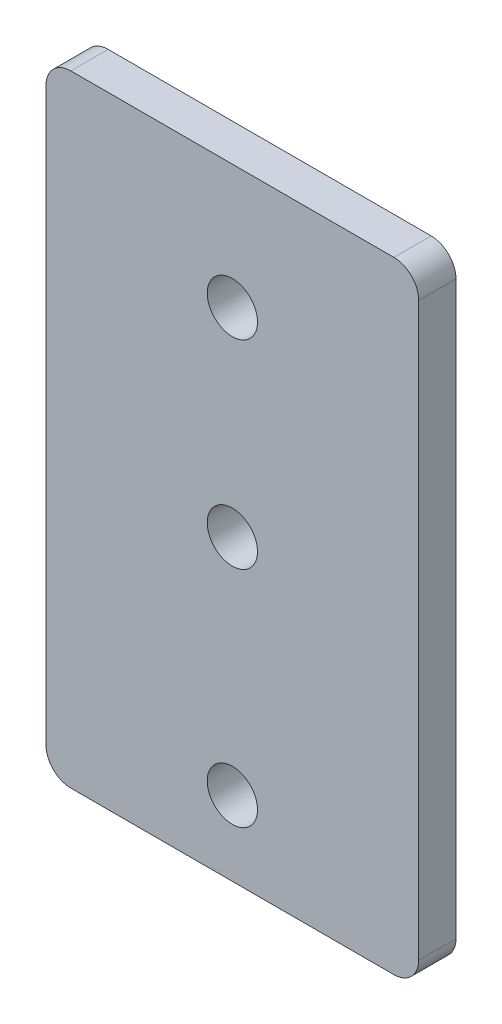
from build123d import *

# Parameters (mm, degrees)
SKETCH_1_W          = 30
SKETCH_1_H          = 50
EXTRUDE_1_DEPTH     = 3
SKETCH_2_R          = 2.025
CUT_EXTRUDE_1_DEPTH = 4
SKETCH_3_R          = 2.025
CUT_EXTRUDE_2_DEPTH = 34
FILLET_1_R          = 2


with BuildPart() as part:
    # 草图1 → 凸台-拉伸1 (new body)
    with BuildSketch(Plane.XY):
        Rectangle(SKETCH_1_W, SKETCH_1_H)
    extrude(amount=EXTRUDE_1_DEPTH)

    # 草图2 → 切除-拉伸1 (cut)
    with BuildSketch(Plane.XY.offset(3)):
        with Locations((0, 15)):
            Circle(SKETCH_2_R)
    extrude(amount=-CUT_EXTRUDE_1_DEPTH, mode=Mode.SUBTRACT)

    # 草图3 → 切除-拉伸2 (cut)
    with BuildSketch(Plane.XY.offset(3)):
        with Locations((0, -1)):
            Circle(SKETCH_3_R)
        with Locations((0, -19)):
            Circle(SKETCH_3_R)
    extrude(amount=-CUT_EXTRUDE_2_DEPTH, mode=Mode.SUBTRACT)

    # 圆角1
    fillet_1_edges = [part.edges().sort_by_distance(p)[0] for p in [
        (15, -25, 1.5),
        (-15, -25, 1.5),
        (-15, 25, 1.5),
        (15, 25, 1.5),
    ]]
    fillet(fillet_1_edges, radius=FILLET_1_R)


solid = part.part
